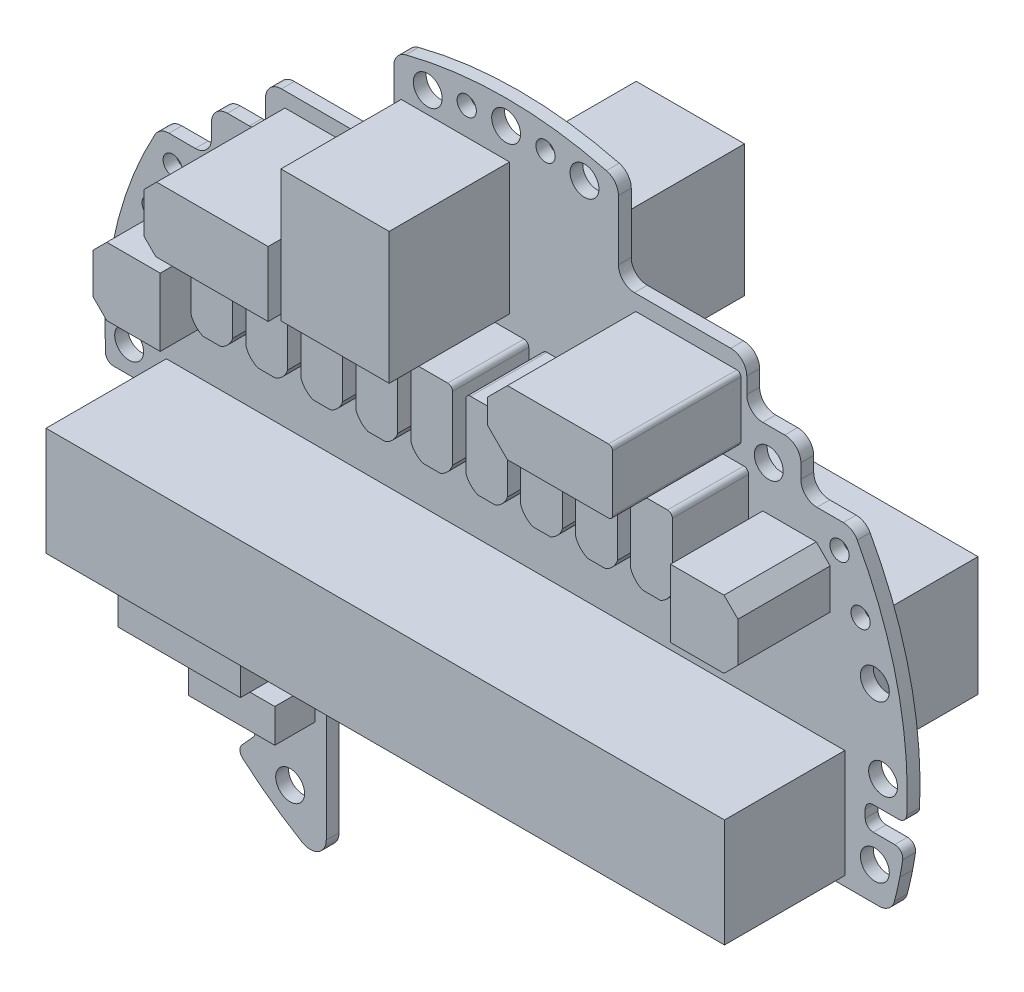
from build123d import *

# Parameters (mm, degrees)
SKETCH12_R          = 1.8
SKETCH12_R_2        = 1.2
BOSS_EXTRUDE1_DEPTH = 1.6
SKETCH13_W          = 84.572999746
SKETCH13_H          = 13.5000508
SKETCH13_W_2        = 13.5000508
SKETCH13_H_2        = 16.4000254
BOSS_EXTRUDE2_DEPTH = 15
SKETCH15_W          = 84.572898146
SKETCH15_H          = 14.877038354
SKETCH15_W_2        = 13.5000508
SKETCH15_H_2        = 16.4000254
BOSS_EXTRUDE4_DEPTH = 15
BOSS_EXTRUDE3_DEPTH = 9.5
BOSS_EXTRUDE7_DEPTH = 16
SKETCH16_W          = 15.24003048
SKETCH16_H          = 7.874015748
BOSS_EXTRUDE5_DEPTH = 9.5
BOSS_EXTRUDE6_DEPTH = 11.5
SKETCH19_W          = 10.7500381
SKETCH19_H          = 4.191008382
BOSS_EXTRUDE8_DEPTH = 5
BOSS_EXTRUDE9_DEPTH = 1.6
FILLET1_R           = 2
SKETCH21_R          = 1.8
CUT_EXTRUDE1_DEPTH  = 17.6
CUT_EXTRUDE2_DEPTH  = 17.6
FILLET2_R           = 1


with BuildPart() as part:
    # Sketch12 → Boss-Extrude1 (new body)
    with BuildSketch(Plane.XY):
        with BuildLine():
            Line((-48.941198882, -3.451079502), (-45.760807722, -3.451079502))
            ThreePointArc((-45.760807722, -3.451079502), (-45.05370094, -3.743972721), (-44.760807722, -4.451079502))
            Line((-44.760807722, -4.451079502), (-44.760782322, -5.420853442))
            ThreePointArc((-44.760782322, -5.420853442), (-45.05367554, -6.127960223), (-45.760782322, -6.420853442))
            Line((-45.760782322, -6.420853442), (-48.442621285, -6.420878842))
            ThreePointArc((-48.442621285, -6.420878842), (-49.201034972, -6.769111647), (-49.431241404, -7.571272442))
            ThreePointArc((-49.431241404, -7.571272442), (-49.262447096, -8.60751229), (-49.071930981, -9.639979296))
            ThreePointArc((-49.071930981, -9.639979296), (-45.363466903, -21.078619154), (-39.031267463, -31.301066802))
            ThreePointArc((-39.031267463, -31.301066802), (-38.336034669, -31.853838803), (-37.47000254, -32.051054102))
            Line((-37.47000254, -32.051054102), (-24.418770638, -32.051054102))
            ThreePointArc((-24.418770638, -32.051054102), (-23.004557075, -31.465267664), (-22.418770638, -30.051054102))
            Line((-22.418770638, -30.051054102), (-22.418770638, -16.051054102))
            ThreePointArc((-22.418770638, -16.051054102), (-21.8329842, -14.63684054), (-20.418770638, -14.051054102))
            Line((-20.418770638, -14.051054102), (46.475793752, -14.051054102))
            ThreePointArc((46.475793752, -14.051054102), (47.700528222, -13.632187666), (48.412268225, -12.551054102))
            ThreePointArc((48.412268225, -12.551054102), (48.763815707, -11.10044034), (49.071907544, -9.63997968))
            ThreePointArc((49.071907544, -9.63997968), (49.262435601, -8.607487186), (49.431242062, -7.571221742))
            ThreePointArc((49.431242062, -7.571221742), (49.201034972, -6.769060847), (48.442621285, -6.420828042))
            Line((48.442621285, -6.420828042), (45.760807722, -6.420828042))
            ThreePointArc((45.760807722, -6.420828042), (45.05370094, -6.127934823), (44.760807722, -5.420828042))
            Line((44.760807722, -5.420828042), (44.760807722, -4.451054102))
            ThreePointArc((44.760807722, -4.451054102), (45.05370094, -3.743947321), (45.760807722, -3.451054102))
            Line((45.760807722, -3.451054102), (48.941198882, -3.451054102))
            ThreePointArc((48.941198882, -3.451054102), (49.630762001, -3.175261232), (49.93997968, -2.5000254))
            ThreePointArc((49.93997968, -2.5000254), (48.710398163, 11.231463252), (43.777546355, 24.10518161))
            ThreePointArc((43.777546355, 24.10518161), (43.043178817, 24.861216412), (42.026441453, 25.138938278))
            Line((42.026441453, 25.138938278), (38.73997968, 25.138938278))
            ThreePointArc((38.73997968, 25.138938278), (37.325766118, 25.724724716), (36.73997968, 27.138938278))
            Line((36.73997968, 27.138938278), (36.73997968, 28.938938278))
            ThreePointArc((36.73997968, 28.938938278), (36.154193242, 30.35315184), (34.73997968, 30.938938278))
            Line((34.73997968, 30.938938278), (31.9999746, 30.938938278))
            ThreePointArc((31.9999746, 30.938938278), (30.585761038, 31.524724716), (29.9999746, 32.938938278))
            Line((29.9999746, 32.938938278), (29.9999746, 34.938938278))
            ThreePointArc((29.9999746, 34.938938278), (29.414188162, 36.35315184), (27.9999746, 36.938938278))
            Line((27.9999746, 36.938938278), (15.9999746, 36.938938278))
            ThreePointArc((15.9999746, 36.938938278), (14.585761038, 37.524724716), (13.9999746, 38.938938278))
            Line((13.9999746, 38.938938278), (13.9999746, 46.424739649))
            ThreePointArc((13.9999746, 46.424739649), (13.581115941, 47.649489479), (12.4999746, 48.361239522))
            ThreePointArc((12.4999746, 48.361239522), (-2.54e-05, 49.948947695), (-12.5000254, 48.361239522))
            ThreePointArc((-12.5000254, 48.361239522), (-13.581166741, 47.649489479), (-14.0000254, 46.424739649))
            Line((-14.0000254, 46.424739649), (-14.0000254, 38.938938278))
            ThreePointArc((-14.0000254, 38.938938278), (-14.585811838, 37.524724716), (-16.0000254, 36.938938278))
            Line((-16.0000254, 36.938938278), (-28.0000254, 36.938938278))
            ThreePointArc((-28.0000254, 36.938938278), (-29.414238962, 36.35315184), (-30.0000254, 34.938938278))
            Line((-30.0000254, 34.938938278), (-30.0000254, 32.938938278))
            ThreePointArc((-30.0000254, 32.938938278), (-30.585811838, 31.524724716), (-32.0000254, 30.938938278))
            Line((-32.0000254, 30.938938278), (-34.74003048, 30.938938278))
            ThreePointArc((-34.74003048, 30.938938278), (-36.154244042, 30.35315184), (-36.74003048, 28.938938278))
            Line((-36.74003048, 28.938938278), (-36.74003048, 27.138938278))
            ThreePointArc((-36.74003048, 27.138938278), (-37.325816918, 25.724724716), (-38.74003048, 25.138938278))
            Line((-38.74003048, 25.138938278), (-42.026492253, 25.138937935))
            ThreePointArc((-42.026492253, 25.138937935), (-43.043229443, 24.861216117), (-43.777596254, 24.105181113))
            ThreePointArc((-43.777596254, 24.105181113), (-48.710442817, 11.231436686), (-49.94000508, -2.5000762))
            ThreePointArc((-49.94000508, -2.5000762), (-49.630769789, -3.175304587), (-48.941198882, -3.451079502))
        make_face()
        with Locations((45.963169926, -9.820929642)):
            Circle(SKETCH12_R, mode=Mode.SUBTRACT)
        with Locations((46.99009398, -0.051054102)):
            Circle(SKETCH12_R, mode=Mode.SUBTRACT)
        with Locations((45.963169926, 9.718821438)):
            Circle(SKETCH12_R, mode=Mode.SUBTRACT)
        with Locations((44.181864364, 15.96977394)):
            Circle(SKETCH12_R_2, mode=Mode.SUBTRACT)
        with Locations((41.55499111, 21.915417831)):
            Circle(SKETCH12_R_2, mode=Mode.SUBTRACT)
        with Locations((32.73990348, 26.939039878)):
            Circle(SKETCH12_R, mode=Mode.SUBTRACT)
        with Locations((9.76987554, 45.912115824)):
            Circle(SKETCH12_R, mode=Mode.SUBTRACT)
        with Locations((4.911861824, 46.681483363)):
            Circle(SKETCH12_R_2, mode=Mode.SUBTRACT)
        with Locations((0, 46.939039878)):
            Circle(SKETCH12_R, mode=Mode.SUBTRACT)
        with Locations((-4.911861824, 46.681483363)):
            Circle(SKETCH12_R_2, mode=Mode.SUBTRACT)
        with Locations((-9.76987554, 45.912115824)):
            Circle(SKETCH12_R, mode=Mode.SUBTRACT)
        with Locations((-32.73990348, 26.939039878)):
            Circle(SKETCH12_R, mode=Mode.SUBTRACT)
        with Locations((-38.300482601, -27.241554483)):
            Circle(SKETCH12_R, mode=Mode.SUBTRACT)
        with Locations((-45.963169926, -9.820929642)):
            Circle(SKETCH12_R, mode=Mode.SUBTRACT)
        with Locations((-46.99009398, -0.051054102)):
            Circle(SKETCH12_R, mode=Mode.SUBTRACT)
        with Locations((-45.963169926, 9.718821438)):
            Circle(SKETCH12_R, mode=Mode.SUBTRACT)
        with Locations((-44.181864364, 15.96977394)):
            Circle(SKETCH12_R_2, mode=Mode.SUBTRACT)
        with Locations((-41.55499111, 21.915417831)):
            Circle(SKETCH12_R_2, mode=Mode.SUBTRACT)
    extrude(amount=BOSS_EXTRUDE1_DEPTH)

    # Sketch13 → Boss-Extrude2 (add)
    with BuildSketch(Plane.XY.offset(1.6)):
        with Locations((-0.065570231, -6.122999746)):
            Rectangle(SKETCH13_W, SKETCH13_H)
        with Locations((-6.323025146, 35.063081026)):
            Rectangle(SKETCH13_W_2, SKETCH13_H_2)
    extrude(amount=BOSS_EXTRUDE2_DEPTH)

    # Sketch15 → Boss-Extrude4 (add)
    with BuildSketch(Plane(origin=(0, 0, 0), x_dir=(-1, 0, 0), z_dir=(0, 0, -1))):
        with Locations((0.065621031, 5.815506731)):
            Rectangle(SKETCH15_W, SKETCH15_H)
        with Locations((-6.365722631, 35.063081026)):
            Rectangle(SKETCH15_W_2, SKETCH15_H_2)
    extrude(amount=BOSS_EXTRUDE4_DEPTH)

    # Sketch14 → Boss-Extrude3 (add)
    with BuildSketch(Plane.XY.offset(1.6)):
        with BuildLine():
            Line((-29.177749555, 25.039497079), (-25.177724155, 25.039497079))
            ThreePointArc((-25.177724155, 25.039497079), (-24.753434686, 24.863761148), (-24.577698755, 24.439471679))
            Line((-24.577698755, 24.439471679), (-24.577698755, 16.464058928))
            ThreePointArc((-24.577698755, 16.464058928), (-25.157235246, 15.494360003), (-26.077724155, 14.839471679))
            Line((-26.077724155, 14.839471679), (-28.277774956, 14.839471679))
            ThreePointArc((-28.277774956, 14.839471679), (-29.198249715, 15.494364008), (-29.777774956, 16.464058928))
            Line((-29.777774956, 16.464058928), (-29.777774956, 24.439471679))
            ThreePointArc((-29.777774956, 24.439471679), (-29.602039025, 24.863761148), (-29.177749555, 25.039497079))
        make_face()
        with BuildLine():
            Line((-22.327749555, 25.039497079), (-18.327724155, 25.039497079))
            ThreePointArc((-18.327724155, 25.039497079), (-17.903434686, 24.863761148), (-17.727698755, 24.439471679))
            Line((-17.727698755, 24.439471679), (-17.727698755, 16.464058928))
            ThreePointArc((-17.727698755, 16.464058928), (-18.307235246, 15.494360003), (-19.227724155, 14.839471679))
            Line((-19.227724155, 14.839471679), (-21.427774956, 14.839471679))
            ThreePointArc((-21.427774956, 14.839471679), (-22.348249715, 15.494364008), (-22.927774956, 16.464058928))
            Line((-22.927774956, 16.464058928), (-22.927774956, 24.439471679))
            ThreePointArc((-22.927774956, 24.439471679), (-22.752039025, 24.863761148), (-22.327749555, 25.039497079))
        make_face()
        with BuildLine():
            Line((-15.477749555, 25.039497079), (-11.477724155, 25.039497079))
            ThreePointArc((-11.477724155, 25.039497079), (-11.053434686, 24.863761148), (-10.877698755, 24.439471679))
            Line((-10.877698755, 24.439471679), (-10.877698755, 16.464058928))
            ThreePointArc((-10.877698755, 16.464058928), (-11.457235246, 15.494360003), (-12.377724155, 14.839471679))
            Line((-12.377724155, 14.839471679), (-14.577774956, 14.839471679))
            ThreePointArc((-14.577774956, 14.839471679), (-15.498249715, 15.494364008), (-16.077774956, 16.464058928))
            Line((-16.077774956, 16.464058928), (-16.077774956, 24.439471679))
            ThreePointArc((-16.077774956, 24.439471679), (-15.902039025, 24.863761148), (-15.477749555, 25.039497079))
        make_face()
        with BuildLine():
            Line((-8.627749555, 25.039497079), (-4.627724155, 25.039497079))
            ThreePointArc((-4.627724155, 25.039497079), (-4.203434686, 24.863761148), (-4.027698755, 24.439471679))
            Line((-4.027698755, 24.439471679), (-4.027698755, 16.464058928))
            ThreePointArc((-4.027698755, 16.464058928), (-4.607235246, 15.494360003), (-5.527724155, 14.839471679))
            Line((-5.527724155, 14.839471679), (-7.727774956, 14.839471679))
            ThreePointArc((-7.727774956, 14.839471679), (-8.648249715, 15.494364008), (-9.227774956, 16.464058928))
            Line((-9.227774956, 16.464058928), (-9.227774956, 24.439471679))
            ThreePointArc((-9.227774956, 24.439471679), (-9.052039025, 24.863761148), (-8.627749555, 25.039497079))
        make_face()
        with BuildLine():
            Line((-1.777749555, 25.039497079), (2.222275845, 25.039497079))
            ThreePointArc((2.222275845, 25.039497079), (2.646565314, 24.863761148), (2.822301245, 24.439471679))
            Line((2.822301245, 24.439471679), (2.822301245, 16.464058928))
            ThreePointArc((2.822301245, 16.464058928), (2.242764754, 15.494360003), (1.322275845, 14.839471679))
            Line((1.322275845, 14.839471679), (-0.877774956, 14.839471679))
            ThreePointArc((-0.877774956, 14.839471679), (-1.798249715, 15.494364008), (-2.377774956, 16.464058928))
            Line((-2.377774956, 16.464058928), (-2.377774956, 24.439471679))
            ThreePointArc((-2.377774956, 24.439471679), (-2.202039025, 24.863761148), (-1.777749555, 25.039497079))
        make_face()
        with BuildLine():
            Line((5.072250445, 25.039497079), (9.072275845, 25.039497079))
            ThreePointArc((9.072275845, 25.039497079), (9.496565314, 24.863761148), (9.672301245, 24.439471679))
            Line((9.672301245, 24.439471679), (9.672301245, 16.464058928))
            ThreePointArc((9.672301245, 16.464058928), (9.092764754, 15.494360003), (8.172275845, 14.839471679))
            Line((8.172275845, 14.839471679), (5.972225044, 14.839471679))
            ThreePointArc((5.972225044, 14.839471679), (5.051750285, 15.494364008), (4.472225044, 16.464058928))
            Line((4.472225044, 16.464058928), (4.472225044, 24.439471679))
            ThreePointArc((4.472225044, 24.439471679), (4.647960975, 24.863761148), (5.072250445, 25.039497079))
        make_face()
        with BuildLine():
            Line((11.922250445, 25.039497079), (15.922275845, 25.039497079))
            ThreePointArc((15.922275845, 25.039497079), (16.346565314, 24.863761148), (16.522301245, 24.439471679))
            Line((16.522301245, 24.439471679), (16.522301245, 16.464058928))
            ThreePointArc((16.522301245, 16.464058928), (15.942764754, 15.494360003), (15.022275845, 14.839471679))
            Line((15.022275845, 14.839471679), (12.822225044, 14.839471679))
            ThreePointArc((12.822225044, 14.839471679), (11.901750285, 15.494364008), (11.322225044, 16.464058928))
            Line((11.322225044, 16.464058928), (11.322225044, 24.439471679))
            ThreePointArc((11.322225044, 24.439471679), (11.497960975, 24.863761148), (11.922250445, 25.039497079))
        make_face()
        with BuildLine():
            Line((18.772250445, 25.039497079), (22.772275845, 25.039497079))
            ThreePointArc((22.772275845, 25.039497079), (23.196565314, 24.863761148), (23.372301245, 24.439471679))
            Line((23.372301245, 24.439471679), (23.372301245, 16.464058928))
            ThreePointArc((23.372301245, 16.464058928), (22.792764754, 15.494360003), (21.872275845, 14.839471679))
            Line((21.872275845, 14.839471679), (19.672225044, 14.839471679))
            ThreePointArc((19.672225044, 14.839471679), (18.751750285, 15.494364008), (18.172225044, 16.464058928))
            Line((18.172225044, 16.464058928), (18.172225044, 24.439471679))
            ThreePointArc((18.172225044, 24.439471679), (18.347960975, 24.863761148), (18.772250445, 25.039497079))
        make_face()
        with BuildLine():
            Line((25.622250445, 25.039497079), (29.622275845, 25.039497079))
            ThreePointArc((29.622275845, 25.039497079), (30.046565314, 24.863761148), (30.222301245, 24.439471679))
            Line((30.222301245, 24.439471679), (30.222301245, 16.464058928))
            ThreePointArc((30.222301245, 16.464058928), (29.642764754, 15.494360003), (28.722275845, 14.839471679))
            Line((28.722275845, 14.839471679), (26.522225044, 14.839471679))
            ThreePointArc((26.522225044, 14.839471679), (25.601750285, 15.494364008), (25.022225044, 16.464058928))
            Line((25.022225044, 16.464058928), (25.022225044, 24.439471679))
            ThreePointArc((25.022225044, 24.439471679), (25.197960975, 24.863761148), (25.622250445, 25.039497079))
        make_face()
    extrude(amount=BOSS_EXTRUDE3_DEPTH)

    # Sketch18 → Boss-Extrude7 (add)
    with BuildSketch(Plane.XY.offset(1.6)):
        Polygon((-13.662687325, 35.087630175), (-27.564135128, 35.087630175), (-29.161798324, 33.487426975), (-29.161798324, 28.488696977), (-27.663195326, 26.987553975), (-13.662687325, 26.987553975), align=None)
        with BuildLine():
            Line((29.263144526, 34.487934976), (29.263144526, 27.488188976))
            ThreePointArc((29.263144526, 27.488188976), (29.116660719, 27.134545783), (28.763017526, 26.988061976))
            Line((28.763017526, 26.988061976), (16.163068326, 26.988061976))
            Line((16.163068326, 26.988061976), (13.662941326, 29.487934976))
            Line((13.662941326, 29.487934976), (13.662941326, 32.488188976))
            Line((13.662941326, 32.488188976), (16.163068326, 34.988061976))
            Line((16.163068326, 34.988061976), (28.763017526, 34.988061976))
            ThreePointArc((28.763017526, 34.988061976), (29.116660719, 34.841578169), (29.263144526, 34.487934976))
        make_face()
    extrude(amount=BOSS_EXTRUDE7_DEPTH)

    # Sketch16 → Boss-Extrude5 (add)
    with BuildSketch(Plane.XY.offset(1.6)):
        with Locations((-31.242062484, -17.907035814)):
            Rectangle(SKETCH16_W, SKETCH16_H)
    extrude(amount=BOSS_EXTRUDE5_DEPTH)

    # Sketch17 → Boss-Extrude6 (add)
    with BuildSketch(Plane.XY.offset(1.6)):
        Polygon((-31.612827026, 20.990271781), (-38.279044958, 20.990271781), (-40.015316231, 19.254000508), (-40.015316231, 14.274066548), (-38.279044958, 12.537795276), (-31.612827026, 12.537795276), align=None)
        Polygon((31.993827788, 21.371272543), (31.993827788, 12.918796038), (38.66004572, 12.918796038), (40.396316993, 14.65506731), (40.396316993, 19.63500127), (38.66004572, 21.371272543), align=None)
    extrude(amount=BOSS_EXTRUDE6_DEPTH)

    # Sketch19 → Boss-Extrude8 (add)
    with BuildSketch(Plane.XY.offset(1.6)):
        with Locations((-29.209309119, -27.242646685)):
            Rectangle(SKETCH19_W, SKETCH19_H)
    extrude(amount=BOSS_EXTRUDE8_DEPTH)

    # Sketch20 → Boss-Extrude9 (add)
    with BuildSketch(Plane.XY.offset(1.6)):
        with BuildLine():
            Line((-22.418770638, -30.051054102), (-22.418770638, -44.743362665))
            ThreePointArc((-22.418770638, -44.743362665), (-31.451560191, -38.920101697), (-39.031267463, -31.301066802))
            ThreePointArc((-39.031267463, -31.301066802), (-38.336034669, -31.853838803), (-37.47000254, -32.051054102))
            Line((-37.47000254, -32.051054102), (-24.418770638, -32.051054102))
            ThreePointArc((-24.418770638, -32.051054102), (-23.004557075, -31.465267664), (-22.418770638, -30.051054102))
        make_face()
    extrude(amount=-BOSS_EXTRUDE9_DEPTH)

    # Fillet1
    fillet1_edges = [part.edges().sort_by_distance(p)[0] for p in [
        (-22.418770638, -44.743362665, 0.8),
    ]]
    fillet(fillet1_edges, radius=FILLET1_R)

    # Sketch21 → Cut-Extrude1 (cut, through all)
    with BuildSketch(Plane.XY.offset(1.6)):
        with Locations((-26.918770638, -37.686353407)):
            Circle(SKETCH21_R)
    extrude(amount=-CUT_EXTRUDE1_DEPTH, mode=Mode.SUBTRACT)

    # Sketch22 → Cut-Extrude2 (cut, through all)
    with BuildSketch(Plane.XY.offset(1.6)):
        with BuildLine():
            Line((-37.054690715, -33.621177453), (-34.09031641, -30.93557045))
            Line((-34.09031641, -30.93557045), (-30.909503775, -34.118718417))
            Line((-30.909503775, -34.118718417), (-33.597285681, -37.081120892))
            ThreePointArc((-33.597285681, -37.081120892), (-35.368322625, -35.393452541), (-37.054690715, -33.621177453))
        make_face()
    extrude(amount=-CUT_EXTRUDE2_DEPTH, mode=Mode.SUBTRACT)

    # Fillet2
    fillet2_edges = [part.edges().sort_by_distance(p)[0] for p in [
        (-33.597285681, -37.081120892, 0.8),
        (-37.054690715, -33.621177453, 0.8),
        (-34.09031641, -30.93557045, 0.8),
        (-30.909503775, -34.118718417, 0.8),
    ]]
    fillet(fillet2_edges, radius=FILLET2_R)


solid = part.part
